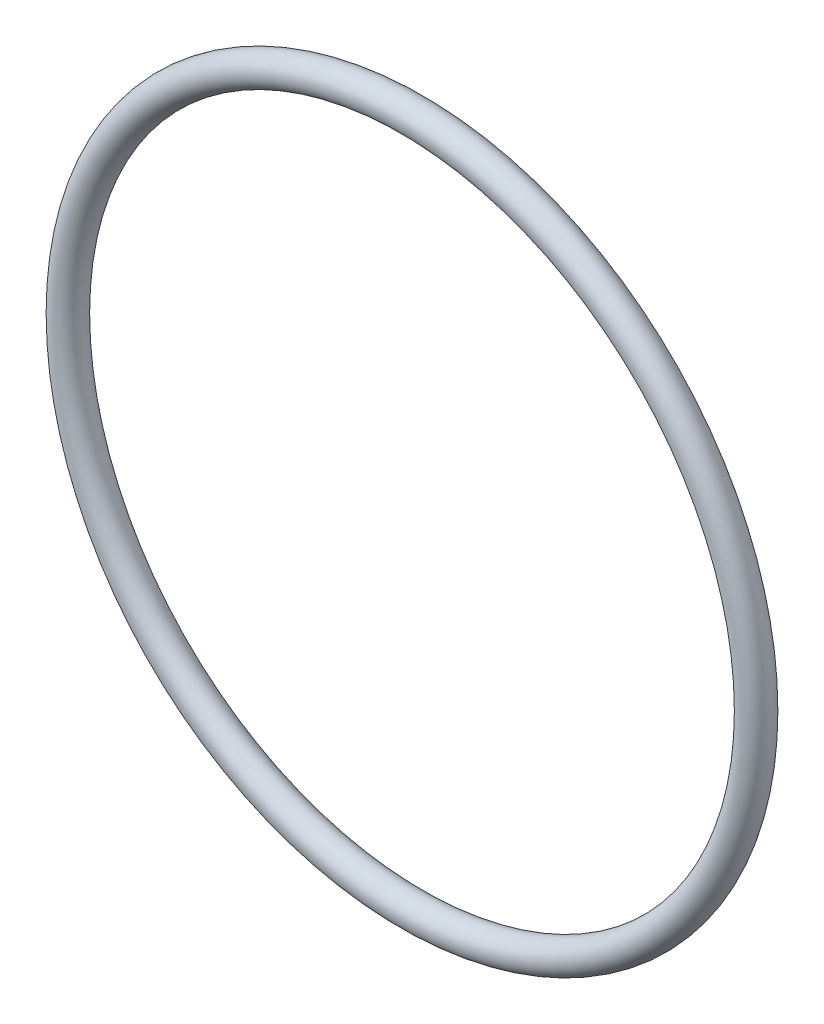
from build123d import *

# Parameters (mm, degrees)
SKETCH6_R = 1.63195


with BuildPart() as part:
    # Sweep1: sweep along a path in Sketch5
    with BuildLine(Plane.XY) as sweep1_path:
        CenterArc((0, 0), 36.46805, 0, 360)
    # Sketch6 → Sweep1 (sweep)
    with BuildSketch(Plane(origin=(0, 0, 0), x_dir=(1, 0, 0), z_dir=(0, 1, 0))):
        with Locations((36.46805, 0)):
            Circle(SKETCH6_R)
    sweep(path=sweep1_path.line)


solid = part.part
